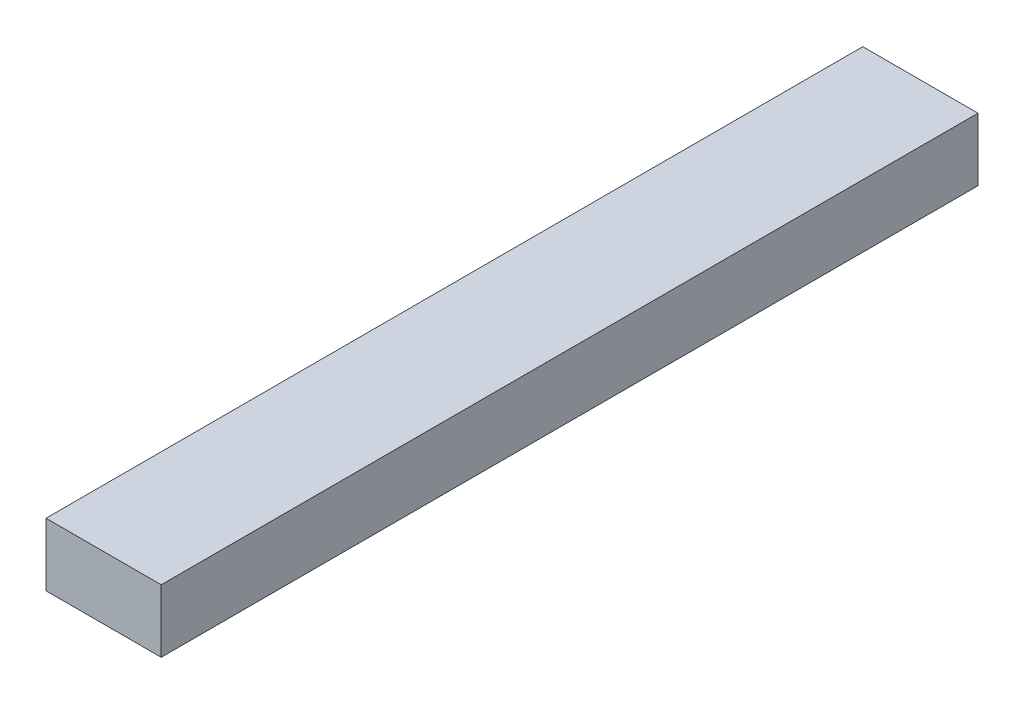
from build123d import *

# Parameters (mm, degrees)
SKETCH_1_W      = 55
SKETCH_1_H      = 390
EXTRUDE_1_DEPTH = 30


with BuildPart() as part:
    # Эскиз1 → Бобышка-Вытянуть1 (new body)
    with BuildSketch(Plane(origin=(0, 0, 0), x_dir=(1, 0, 0), z_dir=(0, 1, 0))):
        with Locations((27.5, 195)):
            Rectangle(SKETCH_1_W, SKETCH_1_H)
    extrude(amount=EXTRUDE_1_DEPTH)


solid = part.part
